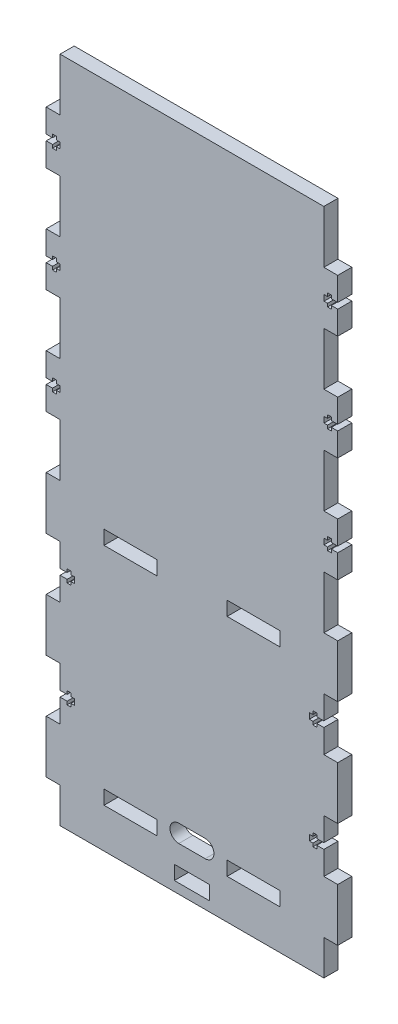
from build123d import *

# Parameters (mm, degrees)
SKETCH1_W           = 150
SKETCH1_H           = 380
SKETCH1_W_2         = 30
SKETCH1_H_2         = 8
SKETCH1_W_3         = 20
BOSS_EXTRUDE1_DEPTH = 8
SKETCH2_W           = 7.9
SKETCH2_H           = 30
BOSS_EXTRUDE2_DEPTH = 8
CUT_EXTRUDE2_DEPTH  = 9


with BuildPart() as part:
    # Sketch1 → Boss-Extrude1 (new body)
    with BuildSketch(Plane.XY):
        with Locations((75, 190)):
            Rectangle(SKETCH1_W, SKETCH1_H)
        with Locations((40, 154.566938385)):
            Rectangle(SKETCH1_W_2, SKETCH1_H_2, mode=Mode.SUBTRACT)
        with Locations((110, 154.566938385)):
            Rectangle(SKETCH1_W_2, SKETCH1_H_2, mode=Mode.SUBTRACT)
        with Locations((40, 26.566938385)):
            Rectangle(SKETCH1_W_2, SKETCH1_H_2, mode=Mode.SUBTRACT)
        with Locations((110, 26.566938385)):
            Rectangle(SKETCH1_W_2, SKETCH1_H_2, mode=Mode.SUBTRACT)
        with Locations((75, 9.5)):
            Rectangle(SKETCH1_W_3, SKETCH1_H_2, mode=Mode.SUBTRACT)
    extrude(amount=BOSS_EXTRUDE1_DEPTH)

    # Sketch2 → Boss-Extrude2 (add)
    with BuildSketch(Plane.XY.offset(8)):
        with Locations((153.95, 335)):
            Rectangle(SKETCH2_W, SKETCH2_H)
        with Locations((-3.95, 335)):
            Rectangle(SKETCH2_W, SKETCH2_H)
        with Locations((153.95, 275)):
            Rectangle(SKETCH2_W, SKETCH2_H)
        with Locations((-3.95, 275)):
            Rectangle(SKETCH2_W, SKETCH2_H)
        with Locations((153.95, 215)):
            Rectangle(SKETCH2_W, SKETCH2_H)
        with Locations((-3.95, 215)):
            Rectangle(SKETCH2_W, SKETCH2_H)
        with Locations((153.95, 155)):
            Rectangle(SKETCH2_W, SKETCH2_H)
        with Locations((-3.95, 155)):
            Rectangle(SKETCH2_W, SKETCH2_H)
        with Locations((153.95, 95)):
            Rectangle(SKETCH2_W, SKETCH2_H)
        with Locations((-3.95, 95)):
            Rectangle(SKETCH2_W, SKETCH2_H)
        with Locations((153.95, 35)):
            Rectangle(SKETCH2_W, SKETCH2_H)
        with Locations((-3.95, 35)):
            Rectangle(SKETCH2_W, SKETCH2_H)
    extrude(amount=-BOSS_EXTRUDE2_DEPTH)

    # Sketch3 → Cut-Extrude2 (cut, through all)
    with BuildSketch(Plane(origin=(0, 0, 0), x_dir=(-1, 0, 0), z_dir=(0, 0, -1))):
        with BuildLine():
            Line((-67.5, 25), (-82.5, 25))
            ThreePointArc((-82.5, 25), (-87.5, 30), (-82.5, 35))
            Line((-82.5, 35), (-67.5, 35))
            ThreePointArc((-67.5, 35), (-62.5, 30), (-67.5, 25))
        make_face()
        Polygon((7.9, 336.65), (4.3, 336.65), (4.3, 338.5), (2.1, 338.5), (2.1, 336.65), (0.1, 336.65), (0.1, 333.35), (2.1, 333.35), (2.1, 331.5), (4.3, 331.5), (4.3, 333.35), (7.9, 333.35), align=None)
        Polygon((-157.9, 213.35), (-154.3, 213.35), (-154.3, 211.5), (-152.1, 211.5), (-152.1, 213.35), (-150.1, 213.35), (-150.1, 216.65), (-152.1, 216.65), (-152.1, 218.5), (-154.3, 218.5), (-154.3, 216.65), (-157.9, 216.65), align=None)
        Polygon((-157.9, 273.35), (-154.3, 273.35), (-154.3, 271.5), (-152.1, 271.5), (-152.1, 273.35), (-150.1, 273.35), (-150.1, 276.65), (-152.1, 276.65), (-152.1, 278.5), (-154.3, 278.5), (-154.3, 276.65), (-157.9, 276.65), align=None)
        Polygon((7.9, 276.65), (4.3, 276.65), (4.3, 278.5), (2.1, 278.5), (2.1, 276.65), (0.1, 276.65), (0.1, 273.35), (2.1, 273.35), (2.1, 271.5), (4.3, 271.5), (4.3, 273.35), (7.9, 273.35), align=None)
        Polygon((7.9, 216.65), (4.3, 216.65), (4.3, 218.5), (2.1, 218.5), (2.1, 216.65), (0.1, 216.65), (0.1, 213.35), (2.1, 213.35), (2.1, 211.5), (4.3, 211.5), (4.3, 213.35), (7.9, 213.35), align=None)
        Polygon((-157.9, 333.35), (-154.3, 333.35), (-154.3, 331.5), (-152.1, 331.5), (-152.1, 333.35), (-150.1, 333.35), (-150.1, 336.65), (-152.1, 336.65), (-152.1, 338.5), (-154.3, 338.5), (-154.3, 336.65), (-157.9, 336.65), align=None)
        Polygon((0, 123.35), (0, 126.65), (-4, 126.65), (-4, 128.5), (-6.2, 128.5), (-6.2, 126.65), (-8.2, 126.65), (-8.2, 123.35), (-6.2, 123.35), (-6.2, 121.5), (-4, 121.5), (-4, 123.35), align=None)
        Polygon((0, 63.35), (0, 66.65), (-4, 66.65), (-4, 68.5), (-6.2, 68.5), (-6.2, 66.65), (-8.2, 66.65), (-8.2, 63.35), (-6.2, 63.35), (-6.2, 61.5), (-4, 61.5), (-4, 63.35), align=None)
        Polygon((-150, 63.35), (-146, 63.35), (-146, 61.5), (-143.8, 61.5), (-143.8, 63.35), (-141.8, 63.35), (-141.8, 66.65), (-143.8, 66.65), (-143.8, 68.5), (-146, 68.5), (-146, 66.65), (-150, 66.65), align=None)
        Polygon((-150, 123.35), (-146, 123.35), (-146, 121.5), (-143.8, 121.5), (-143.8, 123.35), (-141.8, 123.35), (-141.8, 126.65), (-143.8, 126.65), (-143.8, 128.5), (-146, 128.5), (-146, 126.65), (-150, 126.65), align=None)
    extrude(amount=-CUT_EXTRUDE2_DEPTH, mode=Mode.SUBTRACT)


solid = part.part
